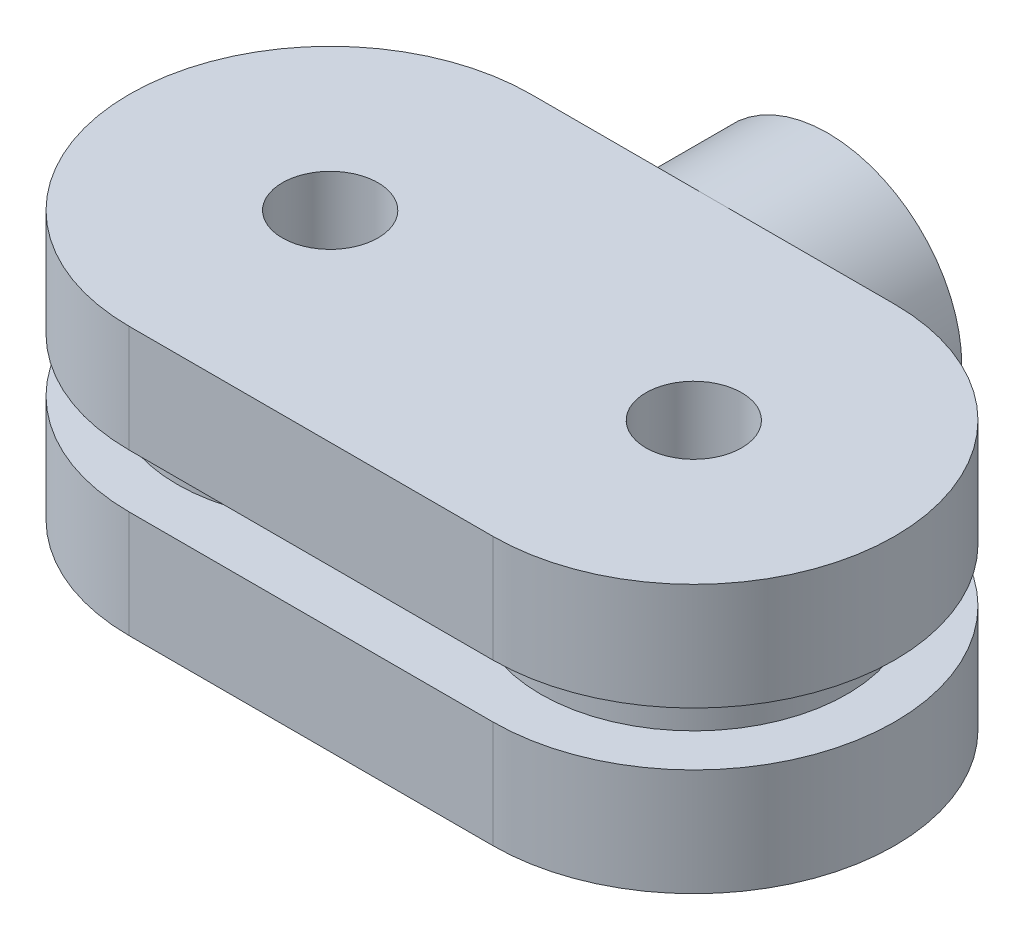
from build123d import *

# Parameters (mm, degrees)
SKETCH_1_R      = 1.25
EXTRUDE_1_DEPTH = 2.8
SKETCH_2_R      = 4
SKETCH_2_R_2    = 1.25
EXTRUDE_2_DEPTH = 1.4
SKETCH_3_R      = 1.25
EXTRUDE_3_DEPTH = 2.8
EXTRUDE_4_DEPTH = 3


with BuildPart() as part:
    # 草图1 → 凸台-拉伸1 (new body)
    with BuildSketch(Plane(origin=(0, 0, 0), x_dir=(1, 0, 0), z_dir=(0, 1, 0))):
        with BuildLine():
            Line((0, 5.25), (9.5, 5.25))
            ThreePointArc((9.5, 5.25), (14.75, 0), (9.5, -5.25))
            Line((9.5, -5.25), (0, -5.25))
            ThreePointArc((0, -5.25), (-5.25, 0), (0, 5.25))
        make_face()
        Circle(SKETCH_1_R, mode=Mode.SUBTRACT)
        with Locations((9.5, 0)):
            Circle(SKETCH_1_R, mode=Mode.SUBTRACT)
    extrude(amount=EXTRUDE_1_DEPTH)

    # 草图2 → 凸台-拉伸2 (add)
    with BuildSketch(Plane(origin=(0, 2.8, 0), x_dir=(1, 0, 0), z_dir=(0, 1, 0))):
        Circle(SKETCH_2_R)
        Circle(SKETCH_2_R_2, mode=Mode.SUBTRACT)
        with Locations((9.5, 0)):
            Circle(SKETCH_2_R)
        with Locations((9.5, 0)):
            Circle(SKETCH_2_R_2, mode=Mode.SUBTRACT)
    extrude(amount=EXTRUDE_2_DEPTH)

    # 草图3 → 凸台-拉伸3 (add)
    with BuildSketch(Plane(origin=(0, 4.2, 0), x_dir=(1, 0, 0), z_dir=(0, 1, 0))):
        with BuildLine():
            Line((0, 5.25), (9.5, 5.25))
            ThreePointArc((9.5, 5.25), (14.75, 0), (9.5, -5.25))
            Line((9.5, -5.25), (0, -5.25))
            ThreePointArc((0, -5.25), (-5.25, 0), (0, 5.25))
        make_face()
        Circle(SKETCH_3_R, mode=Mode.SUBTRACT)
        with Locations((9.5, 0)):
            Circle(SKETCH_3_R, mode=Mode.SUBTRACT)
    extrude(amount=EXTRUDE_3_DEPTH)

    # 草图4 → 凸台-拉伸4 (add)
    with BuildSketch(Plane(origin=(0, 0, -5.25), x_dir=(-1, 0, 0), z_dir=(0, 0, -1))):
        with BuildLine():
            ThreePointArc((-1.932304569, 5.576196633), (-4.75, 7), (-7.567695431, 5.576196633))
            Line((-7.567695431, 5.576196633), (-6.360111675, 4.686398076))
            ThreePointArc((-6.360111675, 4.686398076), (-4.75, 5.5), (-3.139888325, 4.686398076))
            Line((-3.139888325, 4.686398076), (-1.932304569, 5.576196633))
        make_face()
        with BuildLine():
            Line((-6.360111675, 2.313601924), (-7.567695431, 1.423803367))
            ThreePointArc((-7.567695431, 1.423803367), (-4.75, 0), (-1.932304569, 1.423803367))
            Line((-1.932304569, 1.423803367), (-3.139888325, 2.313601924))
            ThreePointArc((-3.139888325, 2.313601924), (-4.75, 1.5), (-6.360111675, 2.313601924))
        make_face()
        with BuildLine():
            Line((-6.360111675, 4.686398076), (-7.567695431, 5.576196633))
            ThreePointArc((-7.567695431, 5.576196633), (-8.168041846, 4.252987343), (-8.17928564, 2.8))
            Line((-8.17928564, 2.8), (-6.6234994, 2.8))
            ThreePointArc((-6.6234994, 2.8), (-6.730785439, 3.77656653), (-6.360111675, 4.686398076))
        make_face()
        with BuildLine():
            ThreePointArc((-1.932304569, 1.423803367), (-1.551614092, 2.078617721), (-1.32071436, 2.8))
            Line((-1.32071436, 2.8), (-2.8765006, 2.8))
            ThreePointArc((-2.8765006, 2.8), (-2.99129812, 2.547651483), (-3.139888325, 2.313601924))
            Line((-3.139888325, 2.313601924), (-1.932304569, 1.423803367))
        make_face()
        with BuildLine():
            ThreePointArc((-1.25, 3.5), (-1.424948571, 4.592718169), (-1.932304569, 5.576196633))
            Line((-1.932304569, 5.576196633), (-3.139888325, 4.686398076))
            ThreePointArc((-3.139888325, 4.686398076), (-2.849970612, 4.124410382), (-2.75, 3.5))
            ThreePointArc((-2.75, 3.5), (-2.781879221, 3.144330771), (-2.8765006, 2.8))
            Line((-2.8765006, 2.8), (-1.32071436, 2.8))
            ThreePointArc((-1.32071436, 2.8), (-1.267723464, 3.148218633), (-1.25, 3.5))
        make_face()
        with BuildLine():
            Line((-6.6234994, 2.8), (-8.17928564, 2.8))
            ThreePointArc((-8.17928564, 2.8), (-7.948385908, 2.078617721), (-7.567695431, 1.423803367))
            Line((-7.567695431, 1.423803367), (-6.360111675, 2.313601924))
            ThreePointArc((-6.360111675, 2.313601924), (-6.50870188, 2.547651483), (-6.6234994, 2.8))
        make_face()
    extrude(amount=EXTRUDE_4_DEPTH)


solid = part.part
